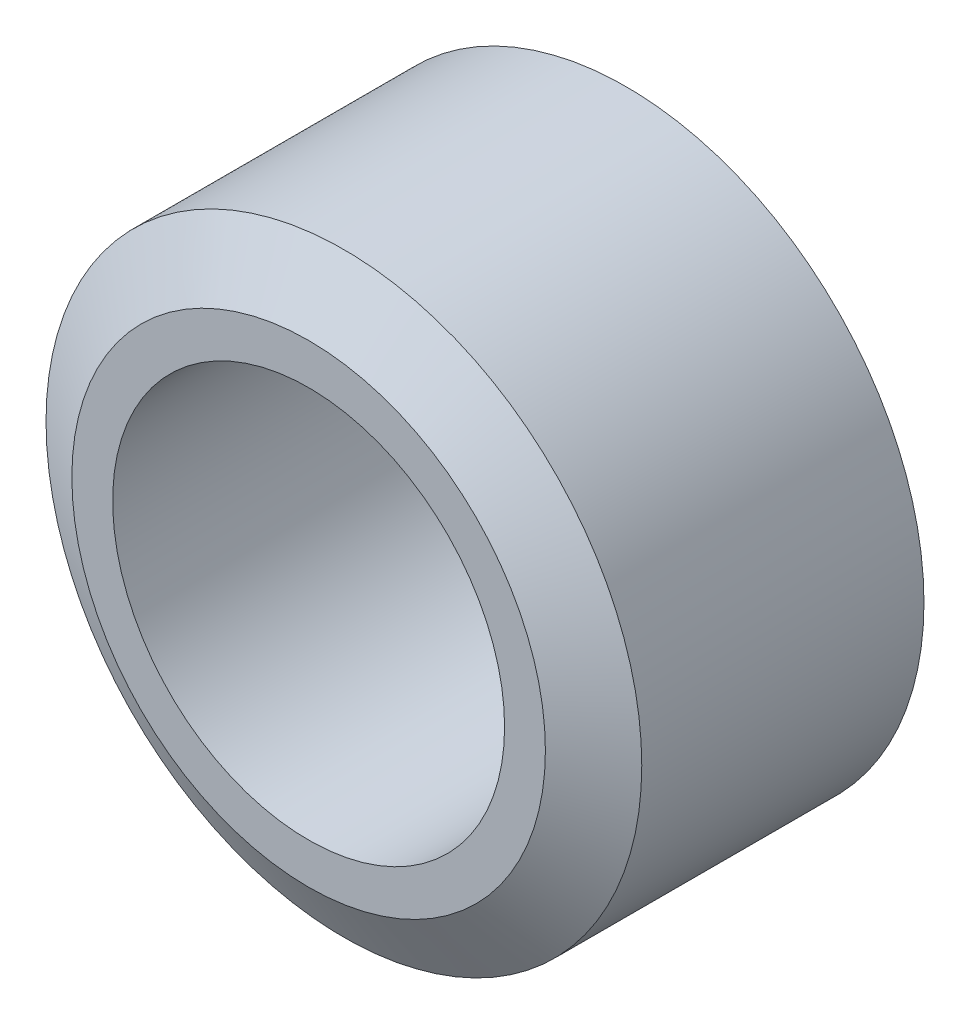
from build123d import *

# Parameters (mm, degrees)
ESQUISSE1_R        = 7.6
ESQUISSE1_R_2      = 5
BOSS_EXTRU_1_DEPTH = 9
CHANFREIN5_SIZE    = 0.9
CHANFREIN5_SIZE2   = 1.558845727
CHANFREIN9_SIZE    = 0.9
CHANFREIN9_SIZE2   = 1.558845727


with BuildPart() as part:
    # Esquisse1 → Boss.-Extru.1 (new body)
    with BuildSketch(Plane.XY):
        Circle(ESQUISSE1_R)
        Circle(ESQUISSE1_R_2, mode=Mode.SUBTRACT)
    extrude(amount=BOSS_EXTRU_1_DEPTH)

    # Chanfrein5
    chanfrein5_edges = [part.edges().sort_by_distance(p)[0] for p in [
        (-7.6, 0, 9),
    ]]
    chanfrein5_side = [part.faces().sort_by_distance(p)[0] for p in [
        (-7.6, 0, 4.5),
    ]]
    chamfer(chanfrein5_edges, length=CHANFREIN5_SIZE, length2=CHANFREIN5_SIZE2, reference=chanfrein5_side[0])

    # Chanfrein9
    chanfrein9_edges = [part.edges().sort_by_distance(p)[0] for p in [
        (-7.6, 0, 0),
    ]]
    chanfrein9_side = [part.faces().sort_by_distance(p)[0] for p in [
        (-7.6, 0, 4.05),
    ]]
    chamfer(chanfrein9_edges, length=CHANFREIN9_SIZE, length2=CHANFREIN9_SIZE2, reference=chanfrein9_side[0])


solid = part.part
